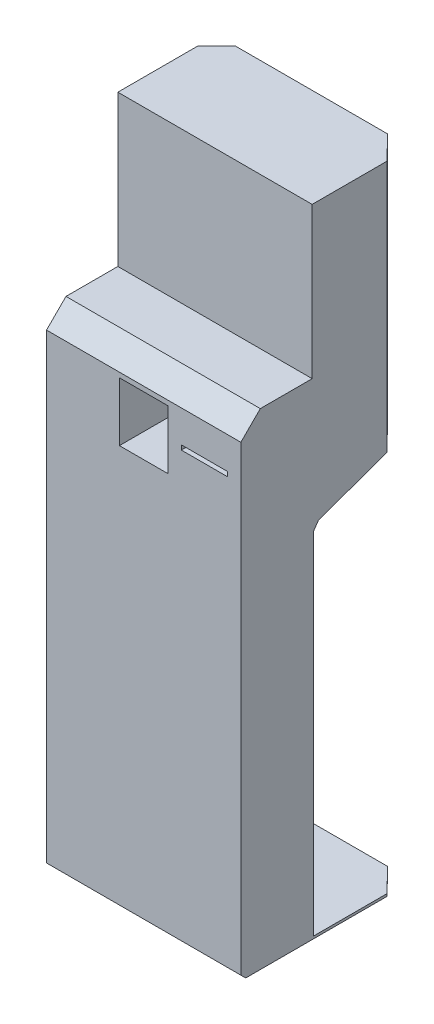
from build123d import *

# Parameters (mm, degrees)
BOSS_EXTRUDE1_DEPTH     = 400
SKETCH2_W               = 100
SKETCH2_H               = 121
SKETCH2_W_2             = 95.3
SKETCH2_H_2             = 9.4
CUT_EXTRUDE1_DEPTH      = 268
CUT_EXTRUDE2_DEPTH      = 1
CUT_EXTRUDE2_DEPTH_BACK = 1311.69690242


with BuildPart() as part:
    # Sketch1 → Boss-Extrude1 (new body)
    with BuildSketch(Plane(origin=(0, 0, 0), x_dir=(0, 0, -1), z_dir=(1, 0, 0))):
        Polygon((0, 0), (-340, 0), (-350, 10), (-350, 960), (-310, 1000), (-203.251091608, 1000), (-203.251091608, 1310.69690242), (-108.48888922, 1310.69690242), (0, 1310.69690242), (0, 1000), (0, 970), (0, 820), (-9.396926208, 806.579798567), (-27.474774195, 800), (-190.603073792, 740.62615458), (-200, 727.205953147), (-200, 5), (0, 5), align=None)
    extrude(amount=BOSS_EXTRUDE1_DEPTH)

    # Sketch2 → Cut-Extrude1 (cut)
    with BuildSketch(Plane.XY.offset(350)):
        with Locations((200, 889.5)):
            Rectangle(SKETCH2_W, SKETCH2_H)
        with Locations((325, 889.5)):
            Rectangle(SKETCH2_W_2, SKETCH2_H_2)
    extrude(amount=-CUT_EXTRUDE1_DEPTH, mode=Mode.SUBTRACT)

    # Sketch3 → Cut-Extrude2 (cut, two sides)
    with BuildSketch(Plane(origin=(0, 0, 0), x_dir=(-1, 0, 0), z_dir=(0, -1, 0))) as cut_extrude2_sk:
        Polygon((32.971910004, -72.804395349), (-67.728153305, 29.569560354), (-322.648629759, 29.569560354), (-423.348693067, -72.804395349), (-423.348693067, 100.069531779), (32.971910004, 100.069531779), align=None)
    extrude(amount=CUT_EXTRUDE2_DEPTH, mode=Mode.SUBTRACT)
    extrude(cut_extrude2_sk.sketch, amount=-CUT_EXTRUDE2_DEPTH_BACK, mode=Mode.SUBTRACT)


solid = part.part
